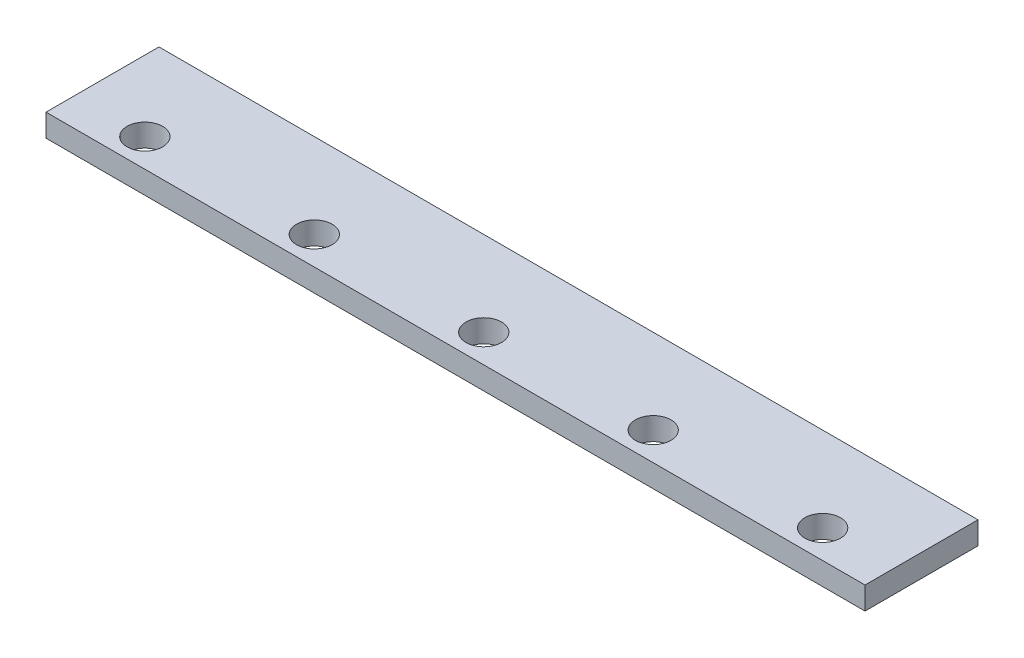
from build123d import *

# Parameters (mm, degrees)
SKETCH1_W           = 580
SKETCH1_H           = 80
SKETCH1_R           = 12.6
BOSS_EXTRUDE1_DEPTH = 16


with BuildPart() as part:
    # Sketch1 → Boss-Extrude1 (new body)
    with BuildSketch(Plane(origin=(0, 0, 0), x_dir=(1, 0, 0), z_dir=(0, 1, 0))):
        with Locations((290, 40)):
            Rectangle(SKETCH1_W, SKETCH1_H)
        with Locations(Location((50, 20, 0), (0, 0, 270))):  # turned: the seam where the file's is
            Circle(SKETCH1_R, mode=Mode.SUBTRACT)
        with Locations(Location((170, 20, 0), (0, 0, 270))):  # turned: the seam where the file's is
            Circle(SKETCH1_R, mode=Mode.SUBTRACT)
        with Locations(Location((290, 20, 0), (0, 0, 270))):  # turned: the seam where the file's is
            Circle(SKETCH1_R, mode=Mode.SUBTRACT)
        with Locations(Location((410, 20, 0), (0, 0, 270))):  # turned: the seam where the file's is
            Circle(SKETCH1_R, mode=Mode.SUBTRACT)
        with Locations(Location((530, 20, 0), (0, 0, 270))):  # turned: the seam where the file's is
            Circle(SKETCH1_R, mode=Mode.SUBTRACT)
    extrude(amount=BOSS_EXTRUDE1_DEPTH)


solid = part.part
